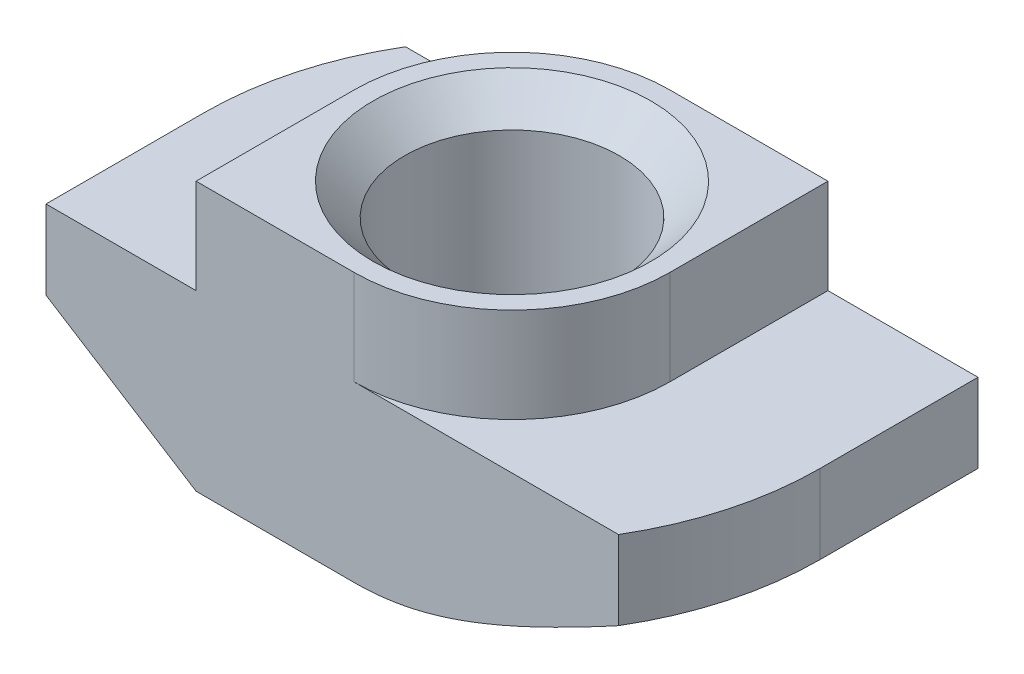
from build123d import *

# Parameters (mm, degrees)
EXTRUDE_1_DEPTH     = 5
CUT_EXTRUDE_1_DEPTH = 3
CUT_EXTRUDE_2_DEPTH = 6.5


with BuildPart() as part:
    # Эскиз1 → Бобышка-Вытянуть1 (new body, symmetric)
    with BuildSketch(Plane.XY):
        Polygon((5, 0), (-5, 0), (-5, -3), (-9.75, -3), (-9.75, -8.5), (9.75, -8.5), (9.75, -3), (5, -3), align=None)
    extrude(amount=EXTRUDE_1_DEPTH, both=True)

    # Эскиз3 → Отверстие обработанное метчиком M81 (revolve, cut)
    with BuildSketch(Plane(origin=(0, 0, 0), x_dir=(0, 0, 1), z_dir=(1, 0, 0))):
        Polygon((0, 0), (0, 8.5), (4.4, 8.5), (3.4, 7.5), (3.4, 1), (4.4, 0), align=None)
    revolve(axis=Axis((0, 6.35, 0), (0, -1, 0)), mode=Mode.SUBTRACT)

    # Эскиз4 → Вырез-Вытянуть1 (cut)
    with BuildSketch(Plane(origin=(0, 0, 0), x_dir=(1, 0, 0), z_dir=(0, 1, 0))):
        with BuildLine():
            Line((-5, 5), (-5, 0))
            ThreePointArc((-5, 0), (-3.535533906, 3.535533906), (0, 5))
            Line((0, 5), (-5, 5))
        make_face()
        with BuildLine():
            Line((0, -5), (5, -5))
            Line((5, -5), (5, 0))
            ThreePointArc((5, 0), (3.535533906, -3.535533906), (0, -5))
        make_face()
    extrude(amount=-CUT_EXTRUDE_1_DEPTH, mode=Mode.SUBTRACT)

    # Эскиз5 → Вырез-Вытянуть2 (cut, through all)
    with BuildSketch(Plane(origin=(0, -3, 0), x_dir=(1, 0, 0), z_dir=(0, 1, 0))):
        with BuildLine():
            Line((-9.75, 0), (-9.75, 5))
            Line((-9.75, 5), (-8.370334521, 5))
            ThreePointArc((-8.370334521, 5), (-9.398756875, 2.59342808), (-9.75, 0))
        make_face()
        with BuildLine():
            Line((9.75, 0), (9.75, -5))
            Line((9.75, -5), (8.370334521, -5))
            ThreePointArc((8.370334521, -5), (9.398756875, -2.59342808), (9.75, 0))
        make_face()
    extrude(amount=-CUT_EXTRUDE_2_DEPTH, mode=Mode.SUBTRACT)

    # Вырез-По траектории1: sweep along a path in Эскиз7
    with BuildLine(Plane.XZ.offset(8.5)) as sweep_1_path:
        Line((0, 9.75), (-9.75, 9.75))
        Line((-9.75, 9.75), (-9.75, 0))
        ThreePointArc((-9.75, 0), (-6.894291117, -6.894291117), (0, -9.75))
        Line((0, -9.75), (9.75, -9.75))
        Line((9.75, -9.75), (9.75, 0))
        ThreePointArc((9.75, 0), (6.894291117, 6.894291117), (0, 9.75))
    # Эскиз6 → Вырез-По траектории1 (sweep, cut)
    with BuildSketch(Plane.XY.offset(5)):
        Polygon((-9.75, -5.5), (-9.75, -8.5), (-5, -8.5), align=None)
    sweep(path=sweep_1_path.line, transition=Transition.RIGHT, mode=Mode.SUBTRACT)


solid = part.part
